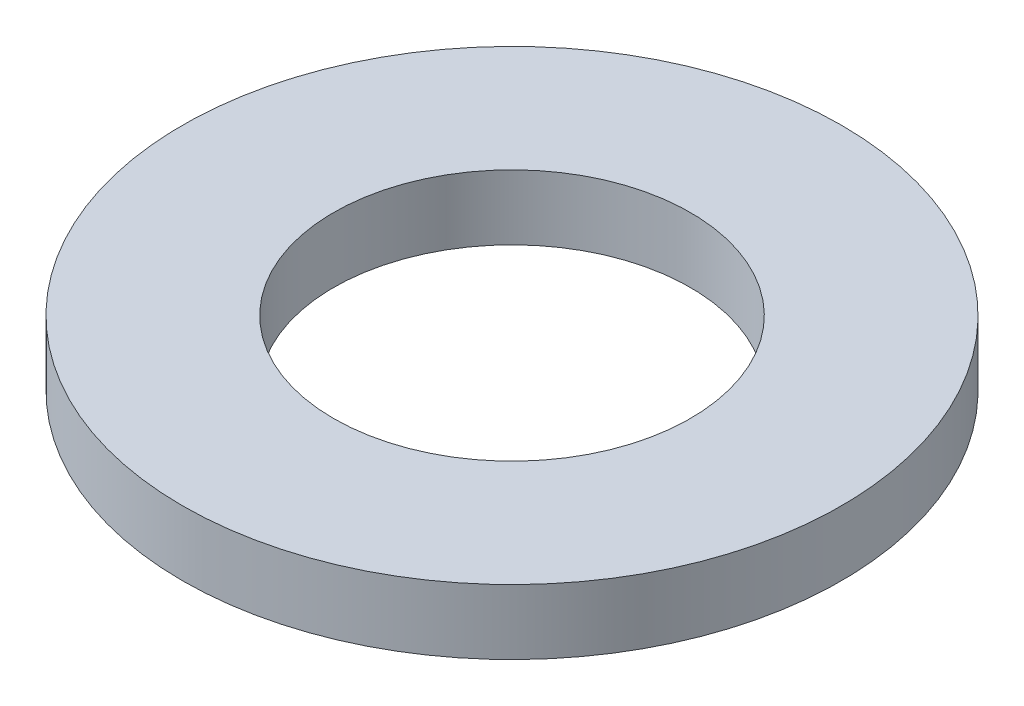
from build123d import *

# Parameters (mm, degrees)
SKETCH1_R           = 38.05
SKETCH1_R_2         = 20.6
BOSS_EXTRUDE1_DEPTH = 7.5


with BuildPart() as part:
    # Sketch1 → Boss-Extrude1 (new body)
    with BuildSketch(Plane(origin=(0, 0, 0), x_dir=(1, 0, 0), z_dir=(0, 1, 0))):
        Circle(SKETCH1_R)
        Circle(SKETCH1_R_2, mode=Mode.SUBTRACT)
    extrude(amount=BOSS_EXTRUDE1_DEPTH)


solid = part.part
